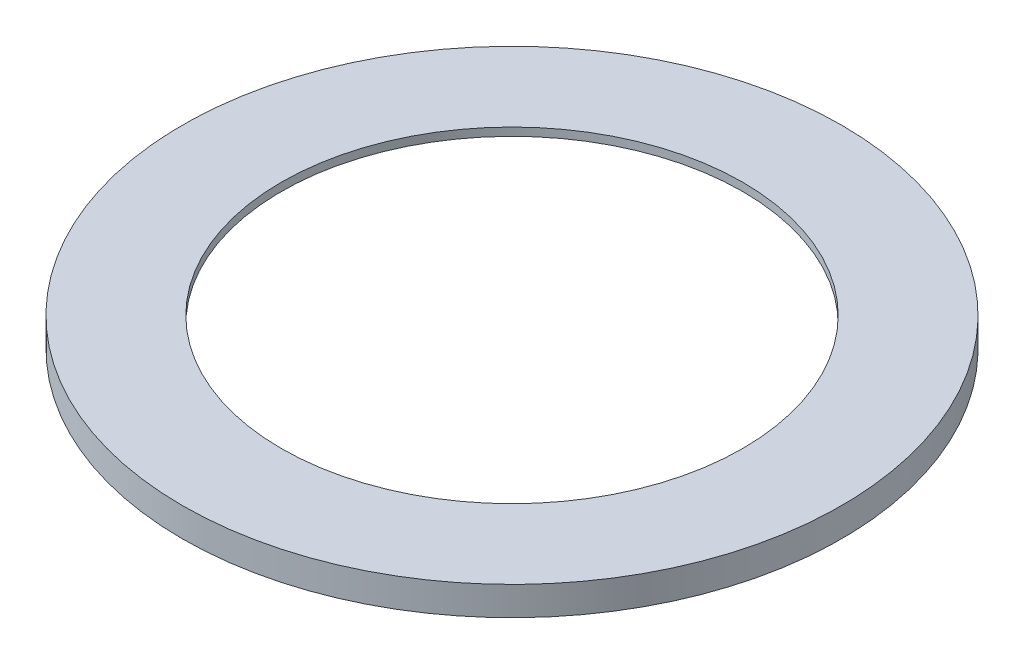
from build123d import *

# Parameters (mm, degrees)
SKETCH1_R           = 57.15
SKETCH1_R_2         = 40
BOSS_EXTRUDE1_DEPTH = 5


with BuildPart() as part:
    # Sketch1 → Boss-Extrude1 (new body)
    with BuildSketch(Plane(origin=(0, 0, 0), x_dir=(1, 0, 0), z_dir=(0, 1, 0))):
        Circle(SKETCH1_R)
        Circle(SKETCH1_R_2, mode=Mode.SUBTRACT)
    extrude(amount=BOSS_EXTRUDE1_DEPTH)

    # Sketch2 → Cut-Revolve1 (revolve, cut)
    with BuildSketch(Plane.XY):
        Polygon((40, 0), (40, 3.6), (57.15, 0), align=None)
    revolve(axis=Axis((0, 0, 0), (0, 1, 0)), mode=Mode.SUBTRACT)


solid = part.part
